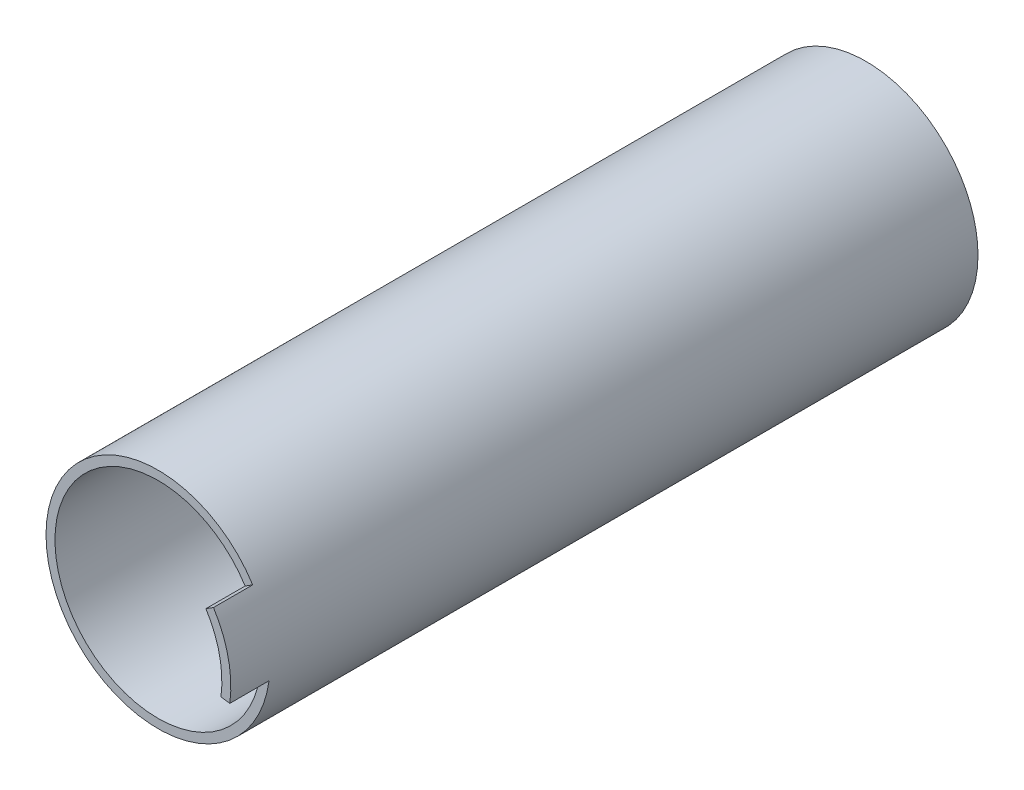
from build123d import *

# Parameters (mm, degrees)
SKETCH_2_R          = 20
SKETCH_2_R_2        = 18.4
EXTRUDE_1_DEPTH     = 126.4
SKETCH_5_R          = 3
EXTRUDE_3_DEPTH     = 126.4
CUT_EXTRUDE1_DEPTH  = 59
CUT_EXTRUDE2_DEPTH  = 59
BOSS_EXTRUDE4_DEPTH = 7
SKETCH3_R           = 3
BOSS_EXTRUDE6_DEPTH = 58.6


with BuildPart() as part:
    # Эскиз2 → Бобышка-Вытянуть1 (new body)
    with BuildSketch(Plane.XY):
        Circle(SKETCH_2_R)
        Circle(SKETCH_2_R_2, mode=Mode.SUBTRACT)
    extrude(amount=EXTRUDE_1_DEPTH)

    # Эскиз5 → Бобышка-Вытянуть3 (add, through all)
    with BuildSketch(Plane(origin=(0, 0, 0), x_dir=(-1, 0, 0), z_dir=(0, 0, -1))):
        with BuildLine():
            Line((0, 18.4), (0, 9.219544457))
            ThreePointArc((0, 9.219544457), (-0.725705562, 6.35915669), (-2.727272727, 4.190702026))
            ThreePointArc((-2.727272727, 4.190702026), (-0.407608696, -4.983357819), (3.372015367, 3.691816946))
            ThreePointArc((3.372015367, 3.691816946), (1.749427822, 6.156705666), (1.498183336, 9.097002072))
            Line((1.498183336, 9.097002072), (2.990014691, 18.155434783))
            ThreePointArc((2.990014691, 18.155434783), (1.5, 18.338756774), (0, 18.4))
        make_face()
        Circle(SKETCH_5_R, mode=Mode.SUBTRACT)
    extrude(amount=-EXTRUDE_3_DEPTH)

    # Sketch1 → Cut-Extrude1 (cut)
    with BuildSketch(Plane(origin=(0, 0, 0), x_dir=(-1, 0, 0), z_dir=(0, 0, -1))):
        with BuildLine():
            Line((0.612543111, 18.389801275), (2.990014691, 18.155434783))
            ThreePointArc((2.990014691, 18.155434783), (-1.805086589, -18.311244152), (0.612543111, 18.389801275))
        make_face()
    extrude(amount=-CUT_EXTRUDE1_DEPTH, mode=Mode.SUBTRACT)

    # Sketch2 → Cut-Extrude2 (cut)
    with BuildSketch(Plane.XY.offset(126.4)):
        with BuildLine():
            Line((-0.612543316, 18.389801268), (-2.990014691, 18.155434783))
            ThreePointArc((-2.990014691, 18.155434783), (1.805086691, -18.311244142), (-0.612543316, 18.389801268))
        make_face()
    extrude(amount=-CUT_EXTRUDE2_DEPTH, mode=Mode.SUBTRACT)

    # Sketch6 → Boss-Extrude4 (add)
    with BuildSketch(Plane.XY.offset(126.4)):
        with BuildLine():
            Line((16.901505151, 10.692947377), (15.549384739, 9.837511587))
            ThreePointArc((15.549384739, 9.837511587), (17.97626922, 3.926034248), (18.234950332, -2.458980763))
            Line((18.234950332, -2.458980763), (19.820598187, -2.672805177))
            ThreePointArc((19.820598187, -2.672805177), (19.539423066, 4.267428531), (16.901505151, 10.692947377))
        make_face()
    extrude(amount=BOSS_EXTRUDE4_DEPTH)


with BuildPart() as body_2:
    # Sketch3 → Boss-Extrude6 (new body)
    with BuildSketch(Plane.XY):
        with BuildLine():
            Line((5, 0), (5, 16.666133325))
            ThreePointArc((5, 16.666133325), (0, 17.4), (-5, 16.666133325))
            Line((-5, 16.666133325), (-5, 0))
            ThreePointArc((-5, 0), (0, -5), (5, 0))
        make_face()
        Circle(SKETCH3_R, mode=Mode.SUBTRACT)
    extrude(amount=BOSS_EXTRUDE6_DEPTH)


solid = Compound([part.part, body_2.part])
